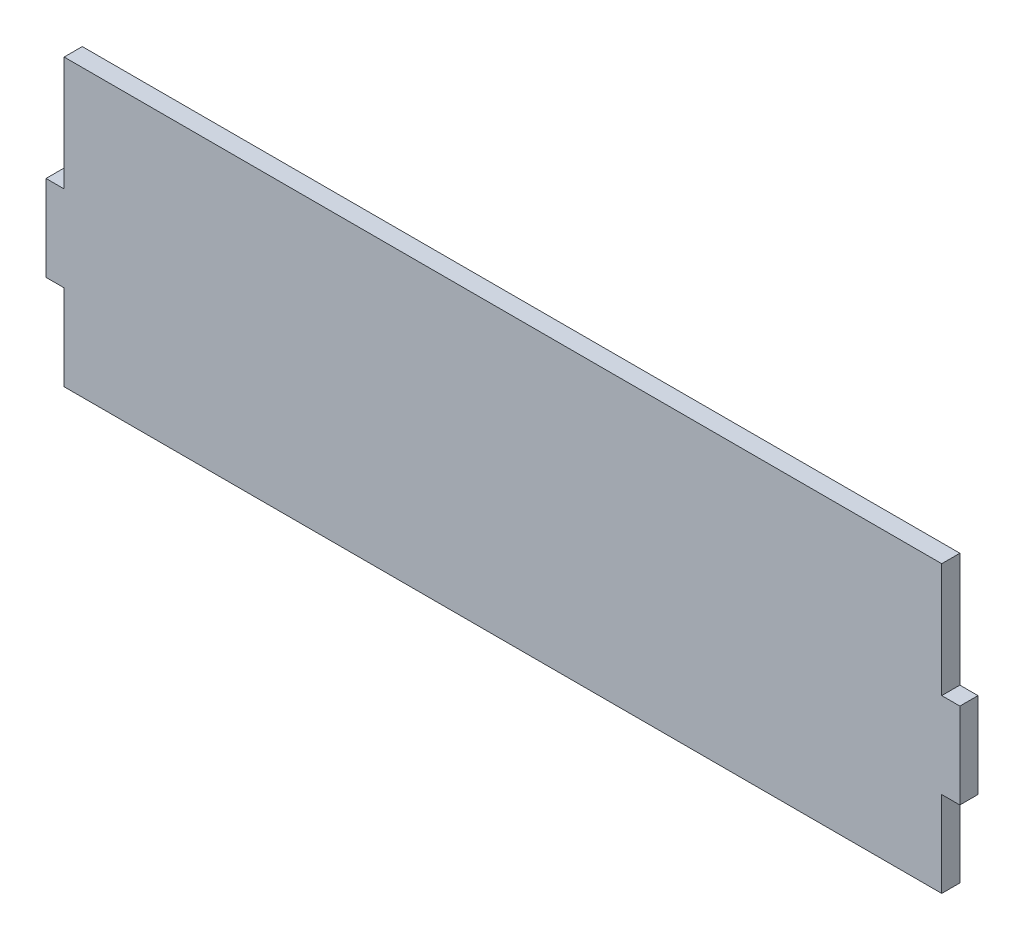
from build123d import *

# Parameters (mm, degrees)
BOSS_EXTRUDE1_DEPTH = 3.175


with BuildPart() as part:
    # Sketch1 → Boss-Extrude1 (new body)
    with BuildSketch(Plane.XY):
        Polygon((-76.825, 0), (76.825, 0), (76.825, 15), (80, 15), (80, 30), (76.825, 30), (76.825, 50), (-76.825, 50), (-76.825, 30), (-80, 30), (-80, 15), (-76.825, 15), align=None)
    extrude(amount=BOSS_EXTRUDE1_DEPTH)


solid = part.part
